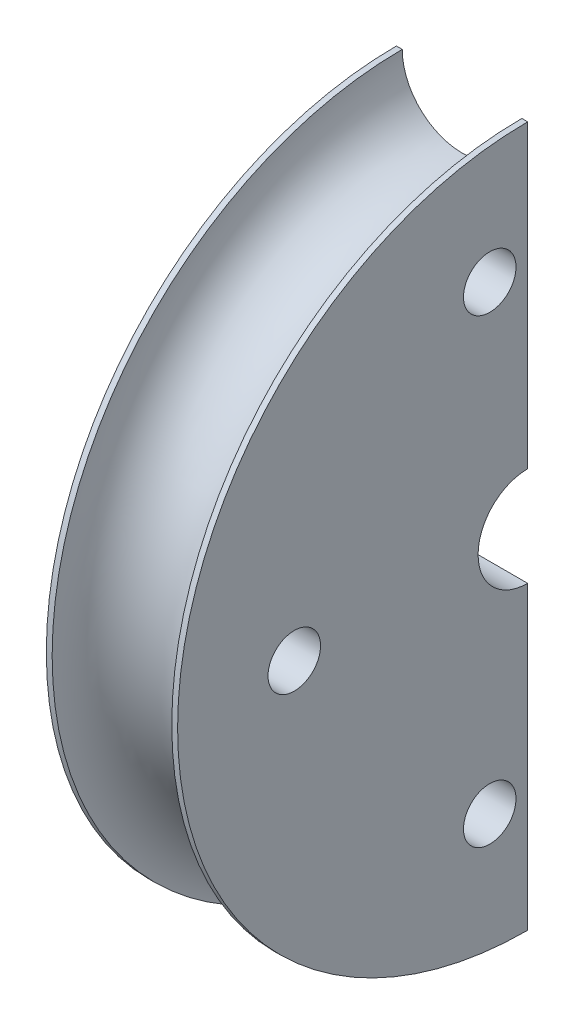
from build123d import *

# Parameters (mm, degrees)
R_VOLUTION1_ANGLE       = 180
ESQUISSE2_R             = 9
ENL_V_MAT_EXTRU_1_DEPTH = 46


with BuildPart() as part:
    # Esquisse1 → Révolution1 (revolve)
    with BuildSketch(Plane.XY):
        with BuildLine():
            Line((0, 17), (0, 120))
            Line((0, 120), (2, 120))
            ThreePointArc((2, 120), (22.5, 99.5), (43, 120))
            Line((43, 120), (45, 120))
            Line((45, 120), (45, 17))
            Line((45, 17), (0, 17))
        make_face()
    revolve(axis=Axis((0, 0, 0), (1, 0, 0)), revolution_arc=R_VOLUTION1_ANGLE)

    # Esquisse2 → Enlèv. mat.-Extru.1 (cut, through all)
    with BuildSketch(Plane.ZY):
        with Locations((80, 0)):
            Circle(ESQUISSE2_R)
        with Locations((13, -78.936683487)):
            Circle(ESQUISSE2_R)
        with Locations((13, 78.936683487)):
            Circle(ESQUISSE2_R)
    extrude(amount=-ENL_V_MAT_EXTRU_1_DEPTH, mode=Mode.SUBTRACT)


solid = part.part
